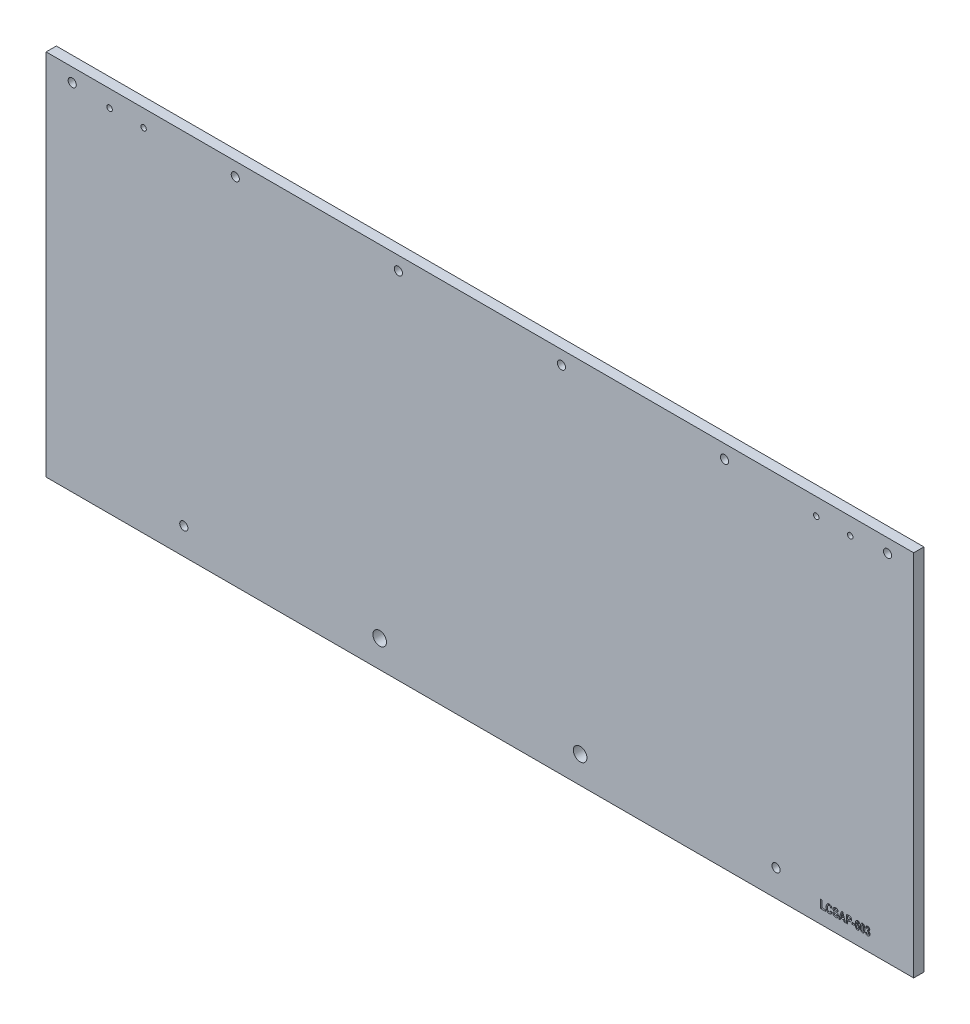
from build123d import *

# Parameters (mm, degrees)
SKETCH1_W           = 405.384
SKETCH1_H           = 172.085
BOSS_EXTRUDE1_DEPTH = 4.7625
SKETCH2_R           = 1.27
SKETCH2_R_2         = 1.905
CUT_EXTRUDE1_DEPTH  = 441.422656192
SKETCH3_R           = 3.175
SKETCH3_R_2         = 1.905
CUT_EXTRUDE2_DEPTH  = 441.422656192
SKETCH4_W           = 1.138051948
SKETCH4_H           = 0.742207792
CUT_EXTRUDE3_DEPTH  = 1.016


with BuildPart() as part:
    # Sketch1 → Boss-Extrude1 (new body)
    with BuildSketch(Plane.XY):
        with Locations((202.692, 86.0425)):
            Rectangle(SKETCH1_W, SKETCH1_H)
    extrude(amount=BOSS_EXTRUDE1_DEPTH)

    # Sketch2 → Cut-Extrude1 (cut, through all)
    with BuildSketch(Plane.XY.offset(4.7625)):
        with Locations((29.6545, 164.1475)):
            Circle(SKETCH2_R)
        with Locations((45.5295, 164.1475)):
            Circle(SKETCH2_R)
        with Locations((359.8545, 164.1475)):
            Circle(SKETCH2_R)
        with Locations((375.7295, 164.1475)):
            Circle(SKETCH2_R)
        with Locations((64.3255, 12.4333)):
            Circle(SKETCH2_R_2)
        with Locations((341.0585, 12.4333)):
            Circle(SKETCH2_R_2)
    extrude(amount=-CUT_EXTRUDE1_DEPTH, mode=Mode.SUBTRACT)

    # Sketch3 → Cut-Extrude2 (cut, through all)
    with BuildSketch(Plane(origin=(0, 0, 0), x_dir=(-1, 0, 0), z_dir=(0, 0, -1))):
        with Locations((-249.52325, 12.7)):
            Circle(SKETCH3_R)
        with Locations((-155.86075, 12.7)):
            Circle(SKETCH3_R)
        with Locations((-393.192, 165.735)):
            Circle(SKETCH3_R_2)
        with Locations((-316.992, 165.735)):
            Circle(SKETCH3_R_2)
        with Locations((-240.792, 165.735)):
            Circle(SKETCH3_R_2)
        with Locations((-164.592, 165.735)):
            Circle(SKETCH3_R_2)
        with Locations((-88.392, 165.735)):
            Circle(SKETCH3_R_2)
        with Locations((-12.192, 165.735)):
            Circle(SKETCH3_R_2)
    extrude(amount=-CUT_EXTRUDE2_DEPTH, mode=Mode.SUBTRACT)

    # Sketch4 → Cut-Extrude3 (cut)
    # profile 1 of 9: a face of its own
    with BuildSketch(Plane.XY.offset(4.7625)):
        with BuildLine():
            Line((382.936337662, 7.33961039), (383.530103896, 7.438571429))
            add(Edge.make_bspline(
                [(383.530103896, 7.438571429), (383.534465361, 7.396911943), (383.542735913, 7.31791395), (383.57061536, 7.208138083), (383.609026971, 7.113272654), (383.659081963, 7.034513967), (383.718284542, 6.972874962), (383.782609155, 6.927010982), (383.853423348, 6.898936238), (383.902772852, 6.895837844), (383.927494318, 6.894285714)],
                knots=[0, 0, 0, 0, 1.355304156, 2.570034305, 3.655187229, 4.657770736, 5.572822417, 6.406427783, 7.201705401, 8, 8, 8, 8], degree=3))
            add(Edge.make_bspline(
                [(383.927494318, 6.894285714), (383.954369082, 6.896371109), (384.007995209, 6.900532322), (384.083931832, 6.934693164), (384.151991741, 6.98961363), (384.211882285, 7.064880462), (384.261910981, 7.158443587), (384.296891671, 7.269817247), (384.318554211, 7.396493997), (384.320676683, 7.48640927), (384.321792208, 7.533666802)],
                knots=[0, 0, 0, 0, 0.773544105, 1.543536286, 2.359413735, 3.279902328, 4.302047568, 5.405756159, 6.636521274, 8, 8, 8, 8], degree=3))
            add(Edge.make_bspline(
                [(384.321792208, 7.533666802), (384.320701978, 7.577841557), (384.318633973, 7.661634564), (384.296698188, 7.779849545), (384.26165536, 7.883629935), (384.212319827, 7.971334053), (384.152755949, 8.041943429), (384.085647353, 8.093874976), (384.010728338, 8.12553658), (383.958449476, 8.129369347), (383.932133117, 8.131298701)],
                knots=[0, 0, 0, 0, 1.339089583, 2.540055761, 3.633194076, 4.648755064, 5.575000742, 6.418014354, 7.203653244, 8, 8, 8, 8], degree=3))
            add(Edge.make_bspline(
                [(383.932133117, 8.131298701), (383.913523103, 8.130777688), (383.874461603, 8.129684107), (383.813640468, 8.117258885), (383.747279143, 8.10092202), (383.702129854, 8.084818278), (383.678545455, 8.07640625)],
                knots=[0, 0, 0, 0, 0.855386015, 1.795412945, 2.848401334, 4, 4, 4, 4], degree=3))
            Line((383.678545455, 8.07640625), (383.743488636, 8.725064935))
            add(Edge.make_bspline(
                [(383.743488636, 8.725064935), (383.782265046, 8.72561685), (383.856339489, 8.726671171), (383.961085951, 8.747921101), (384.054745513, 8.783309257), (384.106282894, 8.821499968), (384.131601461, 8.840261769)],
                knots=[0, 0, 0, 0, 1.123342484, 2.145917298, 3.089152036, 4, 4, 4, 4], degree=3))
            add(Edge.make_bspline(
                [(384.131601461, 8.840261769), (384.15346755, 8.861168223), (384.197222184, 8.903002601), (384.240967389, 8.984919214), (384.268346794, 9.077649265), (384.270950573, 9.143629835), (384.272311688, 9.178120942)],
                knots=[0, 0, 0, 0, 0.955076279, 1.911133417, 2.908052488, 4, 4, 4, 4], degree=3))
            add(Edge.make_bspline(
                [(384.272311688, 9.178120942), (384.271287151, 9.206841442), (384.26932259, 9.261913292), (384.249961995, 9.339627875), (384.216838535, 9.407516555), (384.170527255, 9.464174705), (384.114838537, 9.510099057), (384.050611092, 9.543332648), (383.978915496, 9.56315482), (383.92865305, 9.565186759), (383.902754058, 9.566233766)],
                knots=[0, 0, 0, 0, 1.139827297, 2.185630357, 3.156691862, 4.118036265, 5.071436669, 6.005944982, 6.972512938, 8, 8, 8, 8], degree=3))
            add(Edge.make_bspline(
                [(383.902754058, 9.566233766), (383.876543561, 9.564810806), (383.824851512, 9.562004459), (383.750090262, 9.537461649), (383.68125011, 9.497290885), (383.619055181, 9.441559291), (383.564774617, 9.371073783), (383.523400545, 9.284419124), (383.493758597, 9.183109468), (383.485163921, 9.110034097), (383.480623377, 9.071428571)],
                knots=[0, 0, 0, 0, 0.873177957, 1.72207174, 2.597112569, 3.517339763, 4.493004119, 5.547245842, 6.704216451, 8, 8, 8, 8], degree=3))
            Line((383.480623377, 9.071428571), (382.936337662, 9.17038961))
            add(Edge.make_bspline(
                [(382.936337662, 9.17038961), (382.944156118, 9.212227141), (382.959346915, 9.293514988), (382.98851457, 9.410363455), (383.023349724, 9.518343926), (383.063165506, 9.617579391), (383.109152523, 9.707587086), (383.159024161, 9.789400911), (383.215159381, 9.861864622), (383.276338889, 9.925660284), (383.342782705, 9.980540754), (383.412457353, 10.029210138), (383.487209233, 10.069136395), (383.565431267, 10.102805831), (383.648193676, 10.128194157), (383.734808199, 10.146827227), (383.82593879, 10.157690966), (383.888035767, 10.159219186), (383.919762987, 10.16)],
                knots=[0, 0, 0, 0, 1.323888492, 2.572237035, 3.743577151, 4.851233338, 5.894614541, 6.884670373, 7.827607971, 8.740482364, 9.628407284, 10.504600047, 11.379912067, 12.259984237, 13.150042074, 14.068357082, 15.013065329, 16, 16, 16, 16], degree=3))
            add(Edge.make_bspline(
                [(383.919762987, 10.16), (383.955114111, 10.159140865), (384.024297693, 10.157459502), (384.12511437, 10.143399877), (384.220052001, 10.119957894), (384.309885134, 10.088560702), (384.393823451, 10.046372529), (384.472070071, 9.994888149), (384.545766914, 9.935349563), (384.611045837, 9.865395747), (384.670785001, 9.791490427), (384.72298312, 9.714385808), (384.767268353, 9.635634758), (384.803055697, 9.554539831), (384.831102258, 9.471480803), (384.85098517, 9.386304368), (384.864091412, 9.299393199), (384.865413866, 9.240791773), (384.866077922, 9.211365666)],
                knots=[0, 0, 0, 0, 1.136110954, 2.223415207, 3.264275915, 4.275773003, 5.276148026, 6.275733691, 7.282435396, 8.313756446, 9.34497766, 10.335353855, 11.303404599, 12.245547817, 13.180854416, 14.117297809, 15.054620354, 16, 16, 16, 16], degree=3))
            add(Edge.make_bspline(
                [(384.866077922, 9.211365666), (384.864808256, 9.171837076), (384.862316741, 9.094268586), (384.840643231, 8.980956122), (384.805965476, 8.873471682), (384.756646664, 8.772106388), (384.693693126, 8.676973608), (384.615432729, 8.589248502), (384.525342209, 8.505631272), (384.456202059, 8.458009755), (384.420753247, 8.43359375)],
                knots=[0, 0, 0, 0, 1.011301464, 1.98451623, 2.942285919, 3.895498898, 4.861777034, 5.853076579, 6.899251942, 8, 8, 8, 8], degree=3))
            add(Edge.make_bspline(
                [(384.420753247, 8.43359375), (384.440514765, 8.42734866), (384.480088274, 8.41484253), (384.536125555, 8.387940265), (384.590022678, 8.357198657), (384.640497083, 8.320293293), (384.688599268, 8.278631192), (384.733279121, 8.231215408), (384.775569555, 8.178849419), (384.814412163, 8.121332393), (384.850331643, 8.059319349), (384.881129098, 7.993078699), (384.906368333, 7.922751783), (384.928569581, 7.849397111), (384.944106241, 7.77162953), (384.956922141, 7.690714583), (384.963727469, 7.605685212), (384.964594497, 7.547851423), (384.965038961, 7.51820414)],
                knots=[0, 0, 0, 0, 0.869078506, 1.740376712, 2.603304645, 3.471170013, 4.360750356, 5.271463819, 6.202516728, 7.183826632, 8.182284299, 9.208495033, 10.245655502, 11.31723451, 12.422795936, 13.571969507, 14.755320907, 16, 16, 16, 16], degree=3))
            add(Edge.make_bspline(
                [(384.965038961, 7.51820414), (384.964288367, 7.475115187), (384.962818514, 7.390736196), (384.947165355, 7.267275763), (384.924659471, 7.14912794), (384.891289343, 7.036451896), (384.847730308, 6.929807944), (384.79583497, 6.828253442), (384.733795, 6.732985257), (384.66266414, 6.644846573), (384.586526952, 6.563892425), (384.504492983, 6.493970801), (384.419730707, 6.433930054), (384.330331324, 6.385484011), (384.237768067, 6.347636252), (384.141379602, 6.320170848), (384.041464233, 6.303585552), (383.973429267, 6.301547903), (383.939091315, 6.300519481)],
                knots=[0, 0, 0, 0, 1.166897813, 2.285079005, 3.366956394, 4.423061867, 5.463022754, 6.484271357, 7.508856759, 8.537242389, 9.549763851, 10.515452122, 11.453061742, 12.359226731, 13.264341812, 14.157335176, 15.069987983, 16, 16, 16, 16], degree=3))
            add(Edge.make_bspline(
                [(383.939091315, 6.300519481), (383.90631866, 6.301451079), (383.841539535, 6.303292496), (383.746501708, 6.316668859), (383.655347057, 6.338335876), (383.567942963, 6.36866066), (383.484473431, 6.408050746), (383.40502912, 6.456737831), (383.329105335, 6.513009833), (383.258054796, 6.578191239), (383.1923067, 6.650723034), (383.133462936, 6.730471556), (383.0823434, 6.816915028), (383.038242288, 6.909315186), (383.000877548, 7.007750117), (382.971959761, 7.112672297), (382.94887967, 7.223666816), (382.940585551, 7.300341129), (382.936337662, 7.33961039)],
                knots=[0, 0, 0, 0, 0.984295986, 1.945580355, 2.876939409, 3.795076914, 4.719719193, 5.643810347, 6.589854471, 7.554313356, 8.535437924, 9.526409237, 10.526171694, 11.547669046, 12.598749286, 13.68449719, 14.814099809, 16, 16, 16, 16], degree=3))
        make_face()
    # profile 2 of 9: a face of its own
    with BuildSketch(Plane.XY.offset(4.7625)):
        with BuildLine():
            add(Edge.make_bspline(
                [(381.524596591, 10.16), (381.561541653, 10.158642056), (381.634442261, 10.155962539), (381.740806262, 10.135362476), (381.84206444, 10.101894854), (381.93751721, 10.054417018), (382.027222892, 9.99326615), (382.111406858, 9.918815244), (382.190135086, 9.831096207), (382.263913888, 9.729321754), (382.330213958, 9.610291422), (382.386838692, 9.471863166), (382.434394135, 9.313559035), (382.473144908, 9.13539822), (382.50388473, 8.937127599), (382.524702134, 8.718729001), (382.537956013, 8.480403363), (382.539625516, 8.314808091), (382.540493506, 8.228713474)],
                knots=[0, 0, 0, 0, 0.727503026, 1.435521033, 2.125933754, 2.823035237, 3.52857293, 4.258887692, 5.031802202, 5.846339271, 6.730577678, 7.709342118, 8.787052798, 9.983216815, 11.298799232, 12.737663191, 14.303878888, 16, 16, 16, 16], degree=3))
            add(Edge.make_bspline(
                [(382.540493506, 8.228713474), (382.539623615, 8.142876926), (382.537950654, 7.977797411), (382.524726353, 7.740238487), (382.503792035, 7.522376298), (382.473301933, 7.324566267), (382.434086078, 7.14653446), (382.387201064, 6.988263992), (382.329984078, 6.850071751), (382.263985377, 6.731145664), (382.190069692, 6.629708554), (382.112198735, 6.541462457), (382.027972511, 6.467256499), (381.938438172, 6.406335402), (381.84345208, 6.358412156), (381.742804765, 6.325427124), (381.637054505, 6.304406448), (381.564643049, 6.301832864), (381.527689123, 6.300519481)],
                knots=[0, 0, 0, 0, 1.695059366, 3.259911835, 4.697127445, 6.015833273, 7.209868934, 8.295006778, 9.271397414, 10.15773515, 10.974206064, 11.745554658, 12.477603308, 13.184816065, 13.879016739, 14.571068615, 15.270769761, 16, 16, 16, 16], degree=3))
            add(Edge.make_bspline(
                [(381.527689123, 6.300519481), (381.4907598, 6.301964169), (381.417937409, 6.304813007), (381.311392876, 6.324147751), (381.210208019, 6.357880876), (381.114994223, 6.405400778), (381.025056462, 6.465626699), (380.940915494, 6.539375925), (380.862081037, 6.626248801), (380.802148071, 6.708924057), (380.757082647, 6.782016449), (380.725645196, 6.843152683), (380.696344176, 6.909365445), (380.668140617, 6.980280627), (380.643973235, 7.057285623), (380.620658896, 7.138920081), (380.59973007, 7.225838795), (380.581671522, 7.317772391), (380.56401248, 7.414526873), (380.550886263, 7.516810915), (380.53789814, 7.623925877), (380.52927977, 7.736686656), (380.521210621, 7.854181924), (380.516239514, 7.977160468), (380.511775428, 8.104980324), (380.51178655, 8.192114065), (380.511792208, 8.236444805)],
                knots=[0, 0, 0, 0, 1.088325032, 2.146111092, 3.178950023, 4.221795161, 5.273015815, 6.360545385, 7.511177693, 8.723556364, 9.364476831, 10.040531105, 10.747741516, 11.498134997, 12.288409729, 13.125171687, 14.000253567, 14.922333743, 15.886381247, 16.898284178, 17.961049106, 19.066181515, 20.23079341, 21.432081124, 22.693528529, 24, 24, 24, 24], degree=3))
            add(Edge.make_bspline(
                [(380.511792208, 8.236444805), (380.512659578, 8.322024121), (380.514327494, 8.486589491), (380.527580624, 8.723370655), (380.548387683, 8.940226364), (380.57918643, 9.137205011), (380.61803692, 9.314548312), (380.665245576, 9.472464161), (380.722286301, 9.610452244), (380.788303939, 9.729372756), (380.862215147, 9.830811184), (380.940087196, 9.91905696), (381.024313149, 9.993262997), (381.113847556, 10.054184074), (381.20883363, 10.102107326), (381.30948095, 10.135092356), (381.415231209, 10.156113033), (381.487642665, 10.158686617), (381.524596591, 10.16)],
                knots=[0, 0, 0, 0, 1.69316225, 3.255878705, 4.690734649, 6.001855936, 7.198146525, 8.280455951, 9.258690493, 10.146702072, 10.964714887, 11.737520167, 12.470951286, 13.179499609, 13.875011277, 14.568370088, 15.269392615, 16, 16, 16, 16], degree=3))
        make_face()
        with BuildLine():
            add(Edge.make_bspline(
                [(381.526142857, 9.566233766), (381.512411854, 9.565443985), (381.485039775, 9.563869594), (381.445233676, 9.552577097), (381.40735738, 9.53461032), (381.372129249, 9.508459793), (381.339793792, 9.474472486), (381.308742574, 9.434163281), (381.280191887, 9.386367351), (381.252778504, 9.329911265), (381.229482984, 9.259017749), (381.208968045, 9.170603975), (381.192829604, 9.062226443), (381.179325674, 8.933999314), (381.16759437, 8.786045575), (381.160488242, 8.617915302), (381.155783642, 8.430013259), (381.15529543, 8.298041225), (381.155038961, 8.228713474)],
                knots=[0, 0, 0, 0, 0.441180509, 0.879471584, 1.320574249, 1.783035872, 2.281174677, 2.824866155, 3.41612178, 4.06851155, 4.839013556, 5.809909241, 6.984378085, 8.359905701, 9.955928005, 11.756194428, 13.770637572, 16, 16, 16, 16], degree=3))
            add(Edge.make_bspline(
                [(381.155038961, 8.228713474), (381.155290803, 8.159385515), (381.155769273, 8.027670724), (381.160518476, 7.840028786), (381.167535835, 7.672406996), (381.179445526, 7.524470437), (381.192688002, 7.396471626), (381.209042574, 7.288117787), (381.229527254, 7.199977957), (381.252569102, 7.129219652), (381.280387701, 7.073208682), (381.30877067, 7.025621655), (381.339523911, 6.98526127), (381.372399956, 6.952071103), (381.407327057, 6.925879129), (381.445241542, 6.907950174), (381.485037799, 6.896647929), (381.512411193, 6.895074842), (381.526142857, 6.894285714)],
                knots=[0, 0, 0, 0, 2.233529834, 4.243438314, 6.047070022, 7.637798311, 9.024151416, 10.192614236, 11.165324842, 11.937267167, 12.583397913, 13.175758788, 13.720466603, 14.213631053, 14.676957167, 15.118884396, 15.557994781, 16, 16, 16, 16], degree=3))
            add(Edge.make_bspline(
                [(381.526142857, 6.894285714), (381.540131778, 6.895058462), (381.567762853, 6.896584801), (381.607852943, 6.907906619), (381.645783403, 6.926141624), (381.681695874, 6.951743315), (381.713704777, 6.986058895), (381.74546652, 7.025405762), (381.772653801, 7.07367544), (381.800324855, 7.129786093), (381.823770045, 7.200640358), (381.842798526, 7.28934542), (381.860622497, 7.397405062), (381.873777777, 7.525481179), (381.884453611, 7.673218058), (381.891860989, 7.840796103), (381.896482391, 8.028187925), (381.896983474, 8.159643839), (381.897246753, 8.228713474)],
                knots=[0, 0, 0, 0, 0.450046871, 0.888937661, 1.330643888, 1.800456046, 2.299276457, 2.837157917, 3.424961576, 4.078244013, 4.849800298, 5.820145492, 6.997538181, 8.374947934, 9.964252522, 11.766982255, 13.775885602, 16, 16, 16, 16], degree=3))
            add(Edge.make_bspline(
                [(381.897246753, 8.228713474), (381.896981396, 8.298040709), (381.896476264, 8.430011762), (381.891885182, 8.617920392), (381.884414955, 8.786010094), (381.873819197, 8.934010299), (381.860619977, 9.062341625), (381.842797011, 9.170399292), (381.823775948, 9.259110641), (381.800308448, 9.329947557), (381.77270299, 9.386108924), (381.745207254, 9.434395461), (381.713964004, 9.474404453), (381.681666866, 9.508753641), (381.645790473, 9.534383346), (381.607851122, 9.552611448), (381.567763321, 9.563935042), (381.540131935, 9.565461141), (381.526142857, 9.566233766)],
                knots=[0, 0, 0, 0, 2.228036839, 4.241282185, 6.040478161, 7.634927745, 9.009637465, 10.184722199, 11.153165298, 11.923209159, 12.575211015, 13.161862447, 13.705230643, 14.203073253, 14.671964473, 15.112804857, 15.550835322, 16, 16, 16, 16], degree=3))
        make_face(mode=Mode.SUBTRACT)
    # profile 3 of 9: a face of its own
    with BuildSketch(Plane.XY.offset(4.7625)):
        with BuildLine():
            Line((380.066467532, 9.21987013), (379.472701299, 9.120909091))
            add(Edge.make_bspline(
                [(379.472701299, 9.120909091), (379.468794154, 9.15581089), (379.461435742, 9.221542216), (379.44003125, 9.312781851), (379.410869143, 9.390149504), (379.374826743, 9.454739911), (379.329118147, 9.504976705), (379.275188508, 9.540671644), (379.213273176, 9.562803849), (379.169308527, 9.565060111), (379.146439123, 9.566233766)],
                knots=[0, 0, 0, 0, 1.373243514, 2.586259675, 3.655479581, 4.599729819, 5.463161835, 6.285339117, 7.108072655, 8, 8, 8, 8], degree=3))
            add(Edge.make_bspline(
                [(379.146439123, 9.566233766), (379.13116886, 9.565740064), (379.101053451, 9.564766405), (379.057117252, 9.55392779), (379.014782324, 9.537731042), (378.974331477, 9.514271716), (378.936389571, 9.483718036), (378.900724243, 9.446801314), (378.866448872, 9.404078354), (378.834154131, 9.353528288), (378.804269403, 9.292846163), (378.778593251, 9.219227664), (378.754827407, 9.132712892), (378.734198933, 9.032485036), (378.716911483, 8.918619251), (378.701463534, 8.791272926), (378.689190848, 8.65047907), (378.683817047, 8.552159622), (378.681012987, 8.500856331)],
                knots=[0, 0, 0, 0, 0.57681816, 1.13757792, 1.702731885, 2.288308197, 2.89917272, 3.540654263, 4.227684296, 4.969066731, 5.806621519, 6.781650045, 7.915194099, 9.200750153, 10.65206053, 12.273281648, 14.055390695, 16, 16, 16, 16], degree=3))
            add(Edge.make_bspline(
                [(378.681012987, 8.500856331), (378.699339725, 8.526487854), (378.734866941, 8.576175731), (378.794521249, 8.642292464), (378.857840606, 8.697698761), (378.923678672, 8.743905636), (378.993285864, 8.779992413), (379.066574984, 8.805900022), (379.143795432, 8.820580935), (379.196375876, 8.822868543), (379.222979302, 8.824025974)],
                knots=[0, 0, 0, 0, 1.147521788, 2.224523334, 3.235995272, 4.207625523, 5.148408325, 6.08392744, 7.030550333, 8, 8, 8, 8], degree=3))
            add(Edge.make_bspline(
                [(379.222979302, 8.824025974), (379.252413387, 8.822901019), (379.310913729, 8.820665166), (379.397209001, 8.80532606), (379.479957383, 8.777357019), (379.560303922, 8.740111761), (379.637542489, 8.691951604), (379.711939969, 8.633078444), (379.782668653, 8.563178948), (379.850297992, 8.483888839), (379.913188714, 8.396273963), (379.966800958, 8.299891198), (380.013628828, 8.197441832), (380.051816568, 8.087791515), (380.079711179, 7.970821802), (380.100554802, 7.847113594), (380.114247631, 7.71669057), (380.115373438, 7.627251155), (380.115948052, 7.581601055)],
                knots=[0, 0, 0, 0, 0.832425701, 1.654448883, 2.468028177, 3.296231587, 4.153771285, 5.035920905, 5.973927841, 6.961291119, 7.980526655, 9.018328838, 10.075100388, 11.163029314, 12.296112419, 13.471533877, 14.709464618, 16, 16, 16, 16], degree=3))
            add(Edge.make_bspline(
                [(380.115948052, 7.581601055), (380.115057304, 7.532861279), (380.113324259, 7.43803278), (380.099923143, 7.300095884), (380.078750175, 7.170217533), (380.047689922, 7.048460014), (380.008283137, 6.934337342), (379.960612781, 6.827809525), (379.903116786, 6.729947403), (379.837337182, 6.641209039), (379.765515658, 6.561551864), (379.68901263, 6.4916648), (379.608209133, 6.432414419), (379.523248894, 6.383879926), (379.433665471, 6.346405893), (379.339568206, 6.32052608), (379.241635356, 6.303455673), (379.17485973, 6.301506864), (379.141027192, 6.300519481)],
                knots=[0, 0, 0, 0, 1.298310801, 2.526003934, 3.688615663, 4.800999101, 5.869304757, 6.90177424, 7.905043286, 8.886892483, 9.839696817, 10.758318684, 11.642716176, 12.503696962, 13.359295193, 14.222244813, 15.099282568, 16, 16, 16, 16], degree=3))
            add(Edge.make_bspline(
                [(379.141027192, 6.300519481), (379.103808987, 6.301796468), (379.030317853, 6.304318011), (378.923052082, 6.326170337), (378.820221034, 6.35994548), (378.723238996, 6.409717883), (378.630118288, 6.471964453), (378.542910703, 6.549200524), (378.46058659, 6.639892338), (378.38261411, 6.744053183), (378.311621031, 6.864562284), (378.252028582, 7.003898163), (378.200165239, 7.160277345), (378.159396102, 7.335372017), (378.126020807, 7.527883327), (378.103693069, 7.738887481), (378.089637106, 7.967716505), (378.088062727, 8.126379662), (378.087246753, 8.208612013)],
                knots=[0, 0, 0, 0, 0.734895461, 1.451125905, 2.155006623, 2.867987769, 3.598350511, 4.363563395, 5.163940447, 6.015576444, 6.931075895, 7.920946637, 9.004953514, 10.183535322, 11.470589844, 12.864423707, 14.374885431, 16, 16, 16, 16], degree=3))
            add(Edge.make_bspline(
                [(378.087246753, 8.208612013), (378.088020006, 8.292132546), (378.089512927, 8.453385787), (378.104168365, 8.686148297), (378.128650852, 8.900870408), (378.162134609, 9.097194132), (378.204866426, 9.275850769), (378.258763137, 9.436005245), (378.321729458, 9.578568821), (378.394789503, 9.703084184), (378.476971358, 9.809745021), (378.562824825, 9.90386326), (378.655199206, 9.983512696), (378.753847505, 10.048001611), (378.857836076, 10.098185739), (378.967260148, 10.133876033), (379.082379526, 10.156368495), (379.161282301, 10.15877733), (379.201331575, 10.16)],
                knots=[0, 0, 0, 0, 1.596357934, 3.082091073, 4.455719871, 5.725606172, 6.886943433, 7.963391173, 8.951248094, 9.861153463, 10.715374579, 11.520636501, 12.292728753, 13.040114141, 13.767206519, 14.493146518, 15.235155081, 16, 16, 16, 16], degree=3))
            add(Edge.make_bspline(
                [(379.201331575, 10.16), (379.228943262, 10.15922509), (379.283349587, 10.1576982), (379.363074236, 10.146607054), (379.439588302, 10.128985882), (379.512715366, 10.103321466), (379.582459717, 10.069739515), (379.649148884, 10.029561654), (379.712362653, 9.98188812), (379.771710028, 9.926810651), (379.827833095, 9.865009277), (379.87813351, 9.794861714), (379.922903363, 9.71730798), (379.962240497, 9.632289437), (379.997414118, 9.54027758), (380.025281143, 9.439908229), (380.04967617, 9.332648315), (380.060775265, 9.258101905), (380.066467532, 9.21987013)],
                knots=[0, 0, 0, 0, 0.93854164, 1.849311203, 2.731304215, 3.604197958, 4.478146452, 5.358702106, 6.247156056, 7.16485332, 8.107883078, 9.080606978, 10.093501812, 11.147913945, 12.262634196, 13.438487054, 14.686305819, 16, 16, 16, 16], degree=3))
        make_face()
        with BuildLine():
            add(Edge.make_bspline(
                [(378.730493506, 7.605568182), (378.731054557, 7.577727987), (378.73214653, 7.523542591), (378.737262091, 7.444517001), (378.74688826, 7.370529202), (378.76228175, 7.301820612), (378.77930778, 7.23798265), (378.801104701, 7.179119356), (378.827534397, 7.125649944), (378.857351809, 7.077259749), (378.89002821, 7.034511986), (378.92411494, 6.99748187), (378.958696129, 6.965054189), (378.99534312, 6.939966178), (379.032094351, 6.91864357), (379.071006525, 6.905245559), (379.110721763, 6.89619963), (379.137627517, 6.894923608), (379.151077922, 6.894285714)],
                knots=[0, 0, 0, 0, 1.467223306, 2.855657976, 4.171252668, 5.393844483, 6.563474186, 7.65065082, 8.69526462, 9.701480453, 10.641263037, 11.525539169, 12.352257717, 13.132142237, 13.8615626, 14.583230387, 15.291745363, 16, 16, 16, 16], degree=3))
            add(Edge.make_bspline(
                [(379.151077922, 6.894285714), (379.176887356, 6.895911536), (379.227880988, 6.899123795), (379.299866542, 6.930005666), (379.364027619, 6.97915249), (379.410228957, 7.034088256), (379.442452138, 7.087535402), (379.464205537, 7.134920936), (379.481392073, 7.18886359), (379.497097709, 7.248083264), (379.508608073, 7.313514926), (379.515653965, 7.384858193), (379.521682043, 7.462181791), (379.522011132, 7.515870936), (379.522181818, 7.543717532)],
                knots=[0, 0, 0, 0, 1.10939644, 2.191917695, 3.319954251, 4.574866243, 5.263603829, 6.010279106, 6.819397753, 7.704415383, 8.653663817, 9.683155171, 10.79833729, 12, 12, 12, 12], degree=3))
            add(Edge.make_bspline(
                [(379.522181818, 7.543717532), (379.521959229, 7.572589095), (379.521529515, 7.628326341), (379.516168697, 7.708870985), (379.506806278, 7.783156957), (379.494752579, 7.851700315), (379.478656148, 7.913983953), (379.45930169, 7.970469583), (379.436418215, 8.021008163), (379.401002046, 8.07795815), (379.351834104, 8.138007375), (379.282766452, 8.191288261), (379.20570958, 8.224945772), (379.151404154, 8.228478305), (379.124018263, 8.23025974)],
                knots=[0, 0, 0, 0, 1.176453253, 2.271171319, 3.287245332, 4.22660609, 5.105423138, 5.905880325, 6.657735779, 7.360218118, 8.634991581, 9.796584371, 10.888831116, 12, 12, 12, 12], degree=3))
            add(Edge.make_bspline(
                [(379.124018263, 8.23025974), (379.097451572, 8.228306738), (379.044449174, 8.224410362), (378.96898696, 8.193134486), (378.900779862, 8.142440605), (378.851913958, 8.085397122), (378.816641877, 8.031463664), (378.793436497, 7.984709504), (378.774379094, 7.933267883), (378.757809723, 7.877311019), (378.745994086, 7.816152753), (378.736543814, 7.750390917), (378.731142811, 7.679621968), (378.730715027, 7.630832848), (378.730493506, 7.605568182)],
                knots=[0, 0, 0, 0, 1.160949793, 2.316175707, 3.519822443, 4.855974483, 5.582526876, 6.339918642, 7.136761333, 7.98355107, 8.893612599, 9.862824193, 10.893297682, 12, 12, 12, 12], degree=3))
        make_face(mode=Mode.SUBTRACT)
    # profile 4 of 9: a face of its own
    with BuildSketch(Plane.XY.offset(4.7625)):
        with Locations((377.171857143, 7.760194805)):
            Rectangle(SKETCH4_W, SKETCH4_H)
    # profile 5 of 9: a face of its own
    with BuildSketch(Plane.XY.offset(4.7625)):
        with BuildLine():
            Line((373.881402597, 6.35), (373.881402597, 10.16))
            Line((373.881402597, 10.16), (374.908123377, 10.16))
            add(Edge.make_bspline(
                [(374.908123377, 10.16), (374.953738474, 10.159839173), (375.041109475, 10.159531125), (375.165876327, 10.15756844), (375.278507363, 10.152763497), (375.378532161, 10.146807625), (375.466229134, 10.139289065), (375.541243016, 10.129983109), (375.604286045, 10.12020997), (375.641379757, 10.109792681), (375.6580625, 10.105107549)],
                knots=[0, 0, 0, 0, 1.45237712, 2.781878126, 3.972677768, 5.041396282, 5.972228918, 6.774219171, 7.448710173, 8, 8, 8, 8], degree=3))
            add(Edge.make_bspline(
                [(375.6580625, 10.105107549), (375.681153526, 10.096996221), (375.727097287, 10.080857271), (375.793511616, 10.049524739), (375.856737603, 10.011784724), (375.9166145, 9.967261943), (375.973194602, 9.916745421), (376.026954641, 9.860017674), (376.076725861, 9.796439021), (376.12422109, 9.727527313), (376.167333828, 9.653046821), (376.204774725, 9.572909328), (376.235225321, 9.487227438), (376.26192986, 9.396808642), (376.281774725, 9.300851041), (376.295429469, 9.199827947), (376.304119243, 9.093742693), (376.305328973, 9.021192185), (376.305948052, 8.984064529)],
                knots=[0, 0, 0, 0, 0.846149961, 1.683567978, 2.535100776, 3.389102938, 4.260422696, 5.155850399, 6.088615247, 7.050446182, 8.048882284, 9.061856799, 10.105243332, 11.191356413, 12.320760927, 13.490669576, 14.715852464, 16, 16, 16, 16], degree=3))
            add(Edge.make_bspline(
                [(376.305948052, 8.984064529), (376.305592599, 8.950287155), (376.304894274, 8.883928004), (376.296756855, 8.786655405), (376.284707156, 8.693397475), (376.267069914, 8.604485615), (376.243642205, 8.519876907), (376.215778359, 8.439304344), (376.183665721, 8.362485121), (376.145490682, 8.290714876), (376.103864563, 8.223761432), (376.059617024, 8.161394666), (376.012876404, 8.104508481), (375.963264406, 8.052868083), (375.912153265, 8.005312938), (375.856670882, 7.964872815), (375.800141387, 7.927785517), (375.739195591, 7.896029807), (375.671155684, 7.869703508), (375.593972417, 7.84632597), (375.505751205, 7.82747294), (375.406566956, 7.812390997), (375.296428311, 7.800145834), (375.175500251, 7.790968342), (375.043471661, 7.785558181), (374.951939537, 7.785148487), (374.904257711, 7.784935065)],
                knots=[0, 0, 0, 0, 1.135396723, 2.23060449, 3.279591759, 4.295786631, 5.275377901, 6.228987074, 7.160814112, 8.071657328, 8.958908755, 9.810053931, 10.641024385, 11.43162038, 12.216736813, 12.984447025, 13.736746148, 14.488596033, 15.289898233, 16.186242141, 17.197511819, 18.320073528, 19.558272269, 20.922626145, 22.396903763, 24, 24, 24, 24], degree=3))
            Line((374.904257711, 7.784935065), (374.475168831, 7.784935065))
            Line((374.475168831, 7.784935065), (374.475168831, 6.35))
            Line((374.475168831, 6.35), (373.881402597, 6.35))
        make_face()
        with BuildLine():
            Line((374.475168831, 9.516753247), (374.475168831, 8.428181818))
            Line((374.475168831, 8.428181818), (374.862508523, 8.428181818))
            add(Edge.make_bspline(
                [(374.862508523, 8.428181818), (374.893693154, 8.428316797), (374.953494644, 8.42857564), (375.03933199, 8.430891372), (375.117448008, 8.434640151), (375.187839156, 8.439972366), (375.250284307, 8.446682819), (375.304974396, 8.455228854), (375.351826388, 8.46481264), (375.403560409, 8.480090826), (375.460284228, 8.506269643), (375.521729458, 8.546468708), (375.576646471, 8.596982622), (375.624677391, 8.6566699), (375.66432124, 8.725269258), (375.691897264, 8.802283062), (375.709630316, 8.886100618), (375.711311591, 8.944539149), (375.712181818, 8.974786932)],
                knots=[0, 0, 0, 0, 1.284283312, 2.462817476, 3.536098701, 4.504784959, 5.369772942, 6.121838585, 6.783804212, 7.337847747, 8.3400838, 9.343892165, 10.350558075, 11.399797468, 12.488501389, 13.596588458, 14.755994231, 16, 16, 16, 16], degree=3))
            add(Edge.make_bspline(
                [(375.712181818, 8.974786932), (375.711384868, 9.005564051), (375.709843151, 9.065103021), (375.691107239, 9.150136207), (375.663137711, 9.228307259), (375.62122111, 9.296698323), (375.573023519, 9.356895781), (375.518588759, 9.407685578), (375.457207155, 9.44548849), (375.401357606, 9.469782871), (375.350073519, 9.484188698), (375.301524852, 9.491958454), (375.24377349, 9.499588831), (375.176533018, 9.506801526), (375.099899641, 9.510993116), (375.013800103, 9.513859554), (374.918188286, 9.51642166), (374.851171192, 9.516639378), (374.816120536, 9.516753247)],
                knots=[0, 0, 0, 0, 1.217310155, 2.3549115, 3.434183208, 4.491984437, 5.51587148, 6.484436833, 7.425091316, 8.358344432, 8.888574254, 9.53159621, 10.304262475, 11.197434113, 12.210261746, 13.34451227, 14.611151563, 16, 16, 16, 16], degree=3))
            Line((374.816120536, 9.516753247), (374.475168831, 9.516753247))
        make_face(mode=Mode.SUBTRACT)
    # profile 6 of 9: a face of its own
    with BuildSketch(Plane.XY.offset(4.7625)):
        Polygon((373.485558442, 6.35), (372.865505682, 6.35), (372.594135958, 7.191168831), (371.260481331, 7.191168831), (370.98988474, 6.35), (370.368285714, 6.35), (371.646274756, 10.16), (372.20525, 10.16), align=None)
        Polygon((372.386936282, 7.834415584), (371.926922078, 9.262392451), (371.466907873, 7.834415584), align=None, mode=Mode.SUBTRACT)
    # profile 7 of 9: a face of its own
    with BuildSketch(Plane.XY.offset(4.7625)):
        with BuildLine():
            Line((367.646857143, 7.636493506), (368.240623377, 7.685974026))
            add(Edge.make_bspline(
                [(368.240623377, 7.685974026), (368.245412846, 7.656008762), (368.254752487, 7.597575406), (368.274433605, 7.51356924), (368.296302941, 7.434726607), (368.323681389, 7.362401365), (368.353509737, 7.295007233), (368.388481032, 7.23425654), (368.426410634, 7.17841428), (368.468951449, 7.129157595), (368.515002838, 7.085336371), (368.564536078, 7.047098912), (368.618487478, 7.015411898), (368.675834918, 6.988768725), (368.737466475, 6.968937591), (368.802608978, 6.954042163), (368.871798237, 6.945661413), (368.91915502, 6.944407982), (368.94340138, 6.943766234)],
                knots=[0, 0, 0, 0, 1.283284002, 2.502450598, 3.648036641, 4.741550817, 5.771019705, 6.762197452, 7.702675527, 8.622646947, 9.509464764, 10.388204522, 11.263216913, 12.15103932, 13.057737472, 13.996634539, 14.974290105, 16, 16, 16, 16], degree=3))
            add(Edge.make_bspline(
                [(368.94340138, 6.943766234), (368.967386856, 6.944186798), (369.014174793, 6.945007185), (369.082145297, 6.952077498), (369.146395587, 6.963437092), (369.206286063, 6.980554807), (369.262698766, 7.001617489), (369.31554741, 7.026626407), (369.363395152, 7.058199015), (369.407810425, 7.092687946), (369.446842631, 7.131612405), (369.482122146, 7.172138649), (369.510682728, 7.216212864), (369.535004609, 7.261810888), (369.553543567, 7.309884031), (369.566614506, 7.360213305), (369.575693825, 7.412472182), (369.576294509, 7.448325356), (369.576597403, 7.466404221)],
                knots=[0, 0, 0, 0, 1.24984806, 2.438050946, 3.557771333, 4.64636299, 5.679248938, 6.694516573, 7.68559378, 8.661074055, 9.620421872, 10.554324834, 11.455887309, 12.351123657, 13.244140324, 14.133614264, 15.058880124, 16, 16, 16, 16], degree=3))
            add(Edge.make_bspline(
                [(369.576597403, 7.466404221), (369.575890469, 7.487332254), (369.574517273, 7.527984309), (369.562838529, 7.586763552), (369.542719004, 7.640580823), (369.514116038, 7.689419189), (369.478289599, 7.733857741), (369.433980852, 7.774019126), (369.381011768, 7.809166331), (369.330031355, 7.835636491), (369.281485473, 7.857005829), (369.233858652, 7.87415733), (369.177011577, 7.895549795), (369.109341739, 7.917333775), (369.032422208, 7.942984616), (368.945503743, 7.97119217), (368.84799914, 7.999963563), (368.779739722, 8.020691384), (368.743933036, 8.031564529)],
                knots=[0, 0, 0, 0, 0.920834509, 1.788692479, 2.625355144, 3.438845263, 4.269949672, 5.129384894, 6.060923099, 7.060788299, 7.655274663, 8.394990962, 9.288793567, 10.329357386, 11.524217089, 12.85908646, 14.352378214, 16, 16, 16, 16], degree=3))
            add(Edge.make_bspline(
                [(368.743933036, 8.031564529), (368.711383985, 8.041378661), (368.648321527, 8.060393142), (368.557875219, 8.091921827), (368.473474406, 8.121822593), (368.396903225, 8.155118337), (368.325986951, 8.187048633), (368.262391951, 8.220922353), (368.205264376, 8.255116055), (368.13812602, 8.3013385), (368.063333263, 8.366265077), (367.983864404, 8.454456554), (367.914020355, 8.553442726), (367.85394919, 8.662221854), (367.805230347, 8.778729142), (367.771530705, 8.901416605), (367.749666438, 9.027866855), (367.747108655, 9.113860264), (367.745818182, 9.157246347)],
                knots=[0, 0, 0, 0, 0.995705067, 1.929137906, 2.805643294, 3.617475646, 4.374079425, 5.083250302, 5.726695175, 6.323501674, 7.469021963, 8.618192986, 9.793256335, 11.00968795, 12.251802723, 13.482671819, 14.729937436, 16, 16, 16, 16], degree=3))
            add(Edge.make_bspline(
                [(367.745818182, 9.157246347), (367.747570465, 9.207373179), (367.75101128, 9.30580314), (367.779105953, 9.449533088), (367.82369183, 9.585720796), (367.886708938, 9.712824969), (367.96500504, 9.828812012), (368.058701717, 9.930350985), (368.166143361, 10.016441955), (368.287371083, 10.087524752), (368.423411378, 10.142410741), (368.573870745, 10.181307533), (368.738758082, 10.205717109), (368.853627556, 10.208194605), (368.913249188, 10.209480519)],
                knots=[0, 0, 0, 0, 1.016001525, 1.995039112, 2.958718515, 3.914826359, 4.86299968, 5.787773554, 6.706158304, 7.645676028, 8.628001228, 9.67146541, 10.791401858, 12, 12, 12, 12], degree=3))
            add(Edge.make_bspline(
                [(368.913249188, 10.209480519), (368.958641109, 10.208621856), (369.047328085, 10.206944195), (369.176380073, 10.192981799), (369.297585248, 10.169701468), (369.411464733, 10.138308287), (369.517559453, 10.096733993), (369.615550956, 10.044912076), (369.707008287, 9.985891239), (369.788664509, 9.915347123), (369.863649175, 9.83818105), (369.928813252, 9.751972212), (369.983730903, 9.657398808), (370.03039641, 9.555750547), (370.067578069, 9.445883826), (370.095038352, 9.328057755), (370.113896222, 9.202376615), (370.118514543, 9.115820275), (370.120883117, 9.071428571)],
                knots=[0, 0, 0, 0, 1.161082811, 2.268529788, 3.315920136, 4.315767948, 5.286675817, 6.224491986, 7.147968113, 8.064782936, 8.978748437, 9.896534752, 10.821515985, 11.771513441, 12.753550833, 13.783446476, 14.863207619, 16, 16, 16, 16], degree=3))
            Line((370.120883117, 9.071428571), (369.527116883, 9.021948052))
            add(Edge.make_bspline(
                [(369.527116883, 9.021948052), (369.522938887, 9.046208866), (369.514856498, 9.093141733), (369.499793976, 9.160774379), (369.48041444, 9.22246974), (369.458202288, 9.278855173), (369.431801562, 9.328808649), (369.403223115, 9.373858535), (369.370496606, 9.412599937), (369.322669966, 9.4575897), (369.250935602, 9.502410173), (369.15116393, 9.540103694), (369.035841342, 9.56222349), (368.954068178, 9.564848811), (368.910929789, 9.566233766)],
                knots=[0, 0, 0, 0, 0.959243267, 1.855668837, 2.69732651, 3.476781153, 4.213401683, 4.895802106, 5.551525866, 6.183841498, 7.448472762, 8.815414589, 10.320012641, 12, 12, 12, 12], degree=3))
            add(Edge.make_bspline(
                [(368.910929789, 9.566233766), (368.867806708, 9.565262433), (368.786224061, 9.563424811), (368.671443788, 9.544151393), (368.571633623, 9.512578489), (368.488870295, 9.466590471), (368.422896008, 9.411816718), (368.374468495, 9.349352755), (368.344709548, 9.279021338), (368.341302669, 9.229422533), (368.339584416, 9.204407468)],
                knots=[0, 0, 0, 0, 1.375503163, 2.602253489, 3.70275074, 4.700811603, 5.605681669, 6.421826054, 7.204050882, 8, 8, 8, 8], degree=3))
            add(Edge.make_bspline(
                [(368.339584416, 9.204407468), (368.341250686, 9.179968195), (368.344526452, 9.13192239), (368.369953529, 9.063068292), (368.411831976, 9.000444278), (368.450292011, 8.966752047), (368.470243912, 8.949273539)],
                knots=[0, 0, 0, 0, 0.986511101, 1.93940795, 2.931027269, 4, 4, 4, 4], degree=3))
            add(Edge.make_bspline(
                [(368.470243912, 8.949273539), (368.482428574, 8.94022233), (368.509361354, 8.920215685), (368.557880528, 8.894410518), (368.614841555, 8.865158906), (368.68278083, 8.837347617), (368.759544164, 8.806883355), (368.84701208, 8.777095163), (368.943832341, 8.745369947), (369.012160272, 8.724906886), (369.047774351, 8.714241071)],
                knots=[0, 0, 0, 0, 0.580970997, 1.284168869, 2.101321398, 3.035084219, 4.095219995, 5.266568887, 6.575273271, 8, 8, 8, 8], degree=3))
            add(Edge.make_bspline(
                [(369.047774351, 8.714241071), (369.086006537, 8.702665597), (369.159968038, 8.680272438), (369.265769076, 8.643243425), (369.364168029, 8.608362445), (369.453975496, 8.572083296), (369.535297239, 8.534798392), (369.608879355, 8.497801931), (369.674630375, 8.460996965), (369.750860364, 8.411899438), (369.834529324, 8.343605427), (369.924019142, 8.252552771), (369.998104153, 8.147909945), (370.061798815, 8.033852217), (370.110231325, 7.90692998), (370.145911547, 7.768546913), (370.166702542, 7.617277453), (370.169113028, 7.512342259), (370.170363636, 7.457899756)],
                knots=[0, 0, 0, 0, 1.035756796, 2.003707701, 2.906407247, 3.742850513, 4.51441117, 5.225734541, 5.878106001, 6.467575161, 7.574958109, 8.671458568, 9.767653495, 10.889322485, 12.050953544, 13.27960766, 14.588605383, 16, 16, 16, 16], degree=3))
            add(Edge.make_bspline(
                [(370.170363636, 7.457899756), (370.169601154, 7.417899817), (370.168100321, 7.339165972), (370.152411546, 7.223694361), (370.130042575, 7.112683384), (370.096263044, 7.006576126), (370.053107088, 6.90570159), (370.000715777, 6.809290257), (369.938753772, 6.718214324), (369.867820557, 6.632039569), (369.786543397, 6.553311608), (369.693905766, 6.485156968), (369.590674796, 6.427216104), (369.476334962, 6.381419018), (369.351785158, 6.345022579), (369.216709183, 6.318937719), (369.07080852, 6.303582081), (368.96998358, 6.30156282), (368.917887987, 6.300519481)],
                knots=[0, 0, 0, 0, 0.991804927, 1.952218352, 2.886457782, 3.798464992, 4.709395717, 5.604960052, 6.516496456, 7.438312874, 8.369857157, 9.316183769, 10.2837644, 11.298954172, 12.365211701, 13.498800204, 14.707646267, 16, 16, 16, 16], degree=3))
            add(Edge.make_bspline(
                [(368.917887987, 6.300519481), (368.871458858, 6.301572635), (368.781166898, 6.303620733), (368.649650484, 6.319092048), (368.526278513, 6.345491899), (368.410391331, 6.381304083), (368.302915617, 6.429280089), (368.202518618, 6.486132114), (368.110878011, 6.554753175), (368.027325728, 6.633809943), (367.951562378, 6.723086257), (367.882945216, 6.822553926), (367.823847317, 6.933124839), (367.771548217, 7.053450935), (367.729101768, 7.184754394), (367.692325684, 7.325801163), (367.664766583, 7.477563492), (367.652935984, 7.582549313), (367.646857143, 7.636493506)],
                knots=[0, 0, 0, 0, 1.077126704, 2.094716892, 3.06695406, 4.001175917, 4.903369973, 5.792630967, 6.672819179, 7.55264172, 8.45610307, 9.384912885, 10.350803934, 11.360510561, 12.42508299, 13.549057315, 14.740647766, 16, 16, 16, 16], degree=3))
        make_face()
    # profile 8 of 9: a face of its own
    with BuildSketch(Plane.XY.offset(4.7625)):
        with BuildLine():
            Line((366.607766234, 7.735454545), (367.201532468, 7.488051948))
            add(Edge.make_bspline(
                [(367.201532468, 7.488051948), (367.189269502, 7.438140426), (367.165374507, 7.34088536), (367.12016847, 7.201880536), (367.070424392, 7.072905231), (367.013514373, 6.954681367), (366.951389565, 6.846171726), (366.882381543, 6.748444083), (366.807788629, 6.660998066), (366.727186558, 6.584038), (366.640706048, 6.517820013), (366.550775247, 6.458813065), (366.45507188, 6.410439936), (366.354936051, 6.369596271), (366.249580509, 6.339235795), (366.139805722, 6.316388279), (366.025140509, 6.303313866), (365.947027139, 6.301461421), (365.90730763, 6.300519481)],
                knots=[0, 0, 0, 0, 1.282586353, 2.499182829, 3.646034602, 4.730797578, 5.771318175, 6.763713287, 7.712684321, 8.6363956, 9.539720391, 10.428356747, 11.317388874, 12.212151588, 13.124116906, 14.050177375, 15.008543639, 16, 16, 16, 16], degree=3))
            add(Edge.make_bspline(
                [(365.90730763, 6.300519481), (365.857471737, 6.301639914), (365.759844402, 6.303834816), (365.617387358, 6.327451423), (365.481827209, 6.363332743), (365.35340831, 6.414858543), (365.231978384, 6.480719486), (365.118820231, 6.562297938), (365.011293406, 6.656556871), (364.948773963, 6.730051061), (364.916924107, 6.767491883)],
                knots=[0, 0, 0, 0, 1.053414494, 2.063614103, 3.046293227, 4.01520277, 4.983805463, 5.961130836, 6.961320097, 8, 8, 8, 8], degree=3))
            add(Edge.make_bspline(
                [(364.916924107, 6.767491883), (364.881914716, 6.813717278), (364.81138506, 6.906842608), (364.722838994, 7.060406112), (364.647528865, 7.225384288), (364.585891239, 7.401926668), (364.537847958, 7.590228838), (364.504259466, 7.790380573), (364.484088553, 8.002285057), (364.481452252, 8.147489407), (364.480103896, 8.221755276)],
                knots=[0, 0, 0, 0, 0.898140554, 1.809387162, 2.740718204, 3.705966939, 4.703925369, 5.74945803, 6.848943185, 8, 8, 8, 8], degree=3))
            add(Edge.make_bspline(
                [(364.480103896, 8.221755276), (364.481335717, 8.3001534), (364.483735098, 8.452859791), (364.505337886, 8.67518578), (364.53827041, 8.884786274), (364.587371438, 9.080882222), (364.64888129, 9.264599621), (364.724876535, 9.434792836), (364.813114641, 9.593241826), (364.885106849, 9.687872909), (364.920789773, 9.734776786)],
                knots=[0, 0, 0, 0, 1.171098873, 2.281104103, 3.334483992, 4.338438261, 5.297974877, 6.225356982, 7.120398547, 8, 8, 8, 8], degree=3))
            add(Edge.make_bspline(
                [(364.920789773, 9.734776786), (364.953188104, 9.772691174), (365.017038266, 9.847412301), (365.126173381, 9.94417091), (365.24341876, 10.026419174), (365.368731977, 10.093759609), (365.502673763, 10.146134801), (365.644588573, 10.183091554), (365.795044609, 10.204897518), (365.897957707, 10.207929502), (365.950603084, 10.209480519)],
                knots=[0, 0, 0, 0, 1.017460211, 2.005195831, 2.96880208, 3.936538458, 4.903086366, 5.898753713, 6.925103759, 8, 8, 8, 8], degree=3))
            add(Edge.make_bspline(
                [(365.950603084, 10.209480519), (365.993686208, 10.208449268), (366.078364067, 10.206422392), (366.202528792, 10.190218627), (366.320826219, 10.161726572), (366.434411104, 10.124353887), (366.542286912, 10.07434962), (366.64476557, 10.013672359), (366.742250078, 9.942521593), (366.80133698, 9.887208512), (366.831201705, 9.859251218)],
                knots=[0, 0, 0, 0, 1.062174293, 2.087653736, 3.080296642, 4.058948008, 5.03139012, 6.005719887, 6.992016441, 8, 8, 8, 8], degree=3))
            add(Edge.make_bspline(
                [(366.831201705, 9.859251218), (366.851966358, 9.837704027), (366.894278881, 9.793796912), (366.95125279, 9.719838119), (367.004000743, 9.638386842), (367.051577027, 9.549095485), (367.095807188, 9.452836769), (367.136026427, 9.349117281), (367.171408153, 9.23770106), (367.191335902, 9.160441175), (367.201532468, 9.120909091)],
                knots=[0, 0, 0, 0, 0.858002413, 1.748367619, 2.673305357, 3.63929672, 4.648357542, 5.711115493, 6.828831091, 8, 8, 8, 8], degree=3))
            Line((367.201532468, 9.120909091), (366.607766234, 8.922987013))
            add(Edge.make_bspline(
                [(366.607766234, 8.922987013), (366.602186645, 8.948328186), (366.591329691, 8.997637899), (366.569531687, 9.068798525), (366.542993491, 9.134892606), (366.514119584, 9.197506821), (366.479350595, 9.254475445), (366.442981137, 9.308520471), (366.400334542, 9.356402269), (366.355279596, 9.400636839), (366.306227082, 9.438862839), (366.256017425, 9.473432293), (366.203153682, 9.50217426), (366.147856362, 9.525290027), (366.090780414, 9.54399767), (366.031500535, 9.557153343), (365.970152389, 9.565119973), (365.928464253, 9.565858809), (365.90730763, 9.566233766)],
                knots=[0, 0, 0, 0, 1.200071046, 2.335138942, 3.437621639, 4.493482591, 5.51985659, 6.521917265, 7.50210956, 8.480124453, 9.438987346, 10.374745328, 11.297656865, 12.216555725, 13.143999084, 14.072438006, 15.021767148, 16, 16, 16, 16], degree=3))
            add(Edge.make_bspline(
                [(365.90730763, 9.566233766), (365.877365757, 9.565346023), (365.818437088, 9.563598855), (365.732101514, 9.549698023), (365.650416332, 9.525111329), (365.572151742, 9.492833846), (365.498622885, 9.449830623), (365.429011208, 9.397753115), (365.365188497, 9.335027502), (365.304021162, 9.264471953), (365.248593206, 9.182724483), (365.201531087, 9.088246145), (365.162713382, 8.981374228), (365.129276506, 8.862875209), (365.104259575, 8.731970536), (365.086898593, 8.588862925), (365.076063384, 8.433759907), (365.074618027, 8.326146854), (365.07387013, 8.270462662)],
                knots=[0, 0, 0, 0, 0.827686898, 1.628972485, 2.409099021, 3.181967192, 3.964173723, 4.757978677, 5.579415306, 6.433460257, 7.33665582, 8.302235029, 9.343905073, 10.476376866, 11.703364719, 13.024698166, 14.460435141, 16, 16, 16, 16], degree=3))
            add(Edge.make_bspline(
                [(365.07387013, 8.270462662), (365.074715216, 8.21272473), (365.076342596, 8.101538959), (365.085828912, 7.940949436), (365.103860148, 7.793404446), (365.126941499, 7.658323834), (365.158526166, 7.536497155), (365.197112937, 7.427849796), (365.241558758, 7.33132107), (365.294577857, 7.24817745), (365.353324069, 7.176399752), (365.415782033, 7.114081073), (365.483157574, 7.062022486), (365.553648219, 7.017903133), (365.629189219, 6.984470659), (365.708886894, 6.961723952), (365.792268584, 6.945991159), (365.849504901, 6.944517806), (365.878701705, 6.943766234)],
                knots=[0, 0, 0, 0, 1.588381619, 3.058741945, 4.422565575, 5.675514383, 6.825848758, 7.879737597, 8.8437938, 9.742560847, 10.584031071, 11.391113559, 12.163968987, 12.921455088, 13.673648094, 14.427376256, 15.197789283, 16, 16, 16, 16], degree=3))
            add(Edge.make_bspline(
                [(365.878701705, 6.943766234), (365.900115096, 6.944429419), (365.942593265, 6.945744993), (366.005100258, 6.954122187), (366.065418459, 6.969100452), (366.123556001, 6.989881097), (366.179265105, 7.017298502), (366.233117345, 7.049780166), (366.284024841, 7.088823479), (366.33330852, 7.133155242), (366.379791921, 7.184144605), (366.422274197, 7.24276801), (366.461745033, 7.307977707), (366.497965809, 7.380178118), (366.531167531, 7.458905197), (366.56044169, 7.544763079), (366.586932085, 7.63732312), (366.600687752, 7.702114021), (366.607766234, 7.735454545)],
                knots=[0, 0, 0, 0, 0.874040642, 1.73385169, 2.568061146, 3.406503852, 4.248567505, 5.09821747, 5.96915136, 6.862782357, 7.800986125, 8.779254107, 9.812897901, 10.908933612, 12.073249979, 13.297367906, 14.609261928, 16, 16, 16, 16], degree=3))
        make_face()
    # profile 9 of 9: a face of its own
    with BuildSketch(Plane.XY.offset(4.7625)):
        Polygon((361.956597403, 6.35), (361.956597403, 10.16), (362.550363636, 10.16), (362.550363636, 6.993246753), (364.183220779, 6.993246753), (364.183220779, 6.35), align=None)
    extrude(amount=-CUT_EXTRUDE3_DEPTH, mode=Mode.SUBTRACT)


solid = part.part
